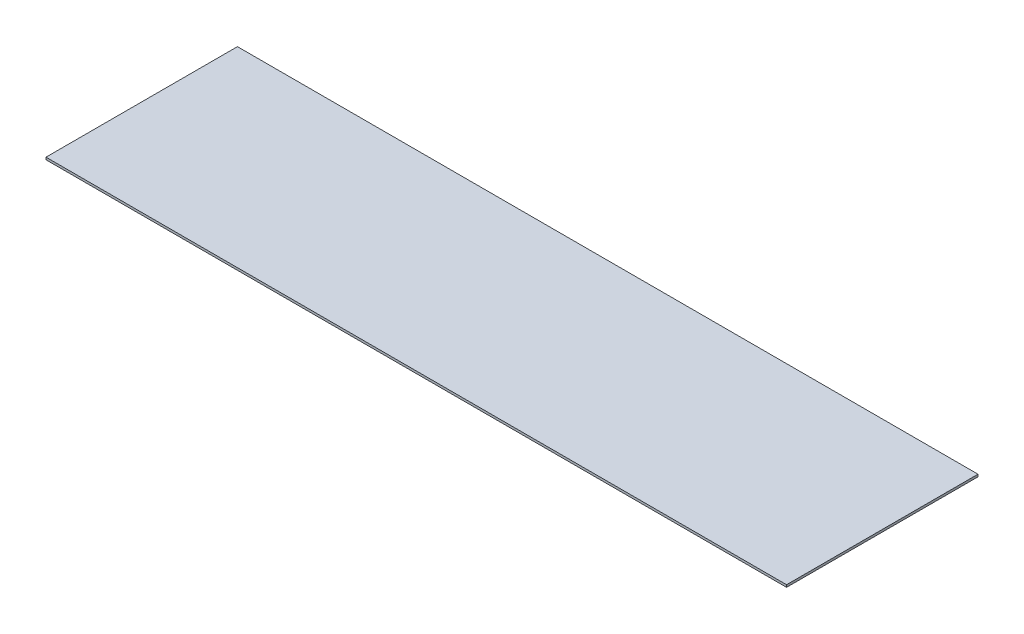
from build123d import *

# Parameters (mm, degrees)
SKETCH2_W           = 132.08
SKETCH2_H           = 1.5875
BOSS_EXTRUDE2_DEPTH = 510.9718


with BuildPart() as part:
    # Sketch2 → Boss-Extrude2 (new body)
    with BuildSketch(Plane(origin=(0, 0, 0), x_dir=(0, 0, -1), z_dir=(1, 0, 0))):
        with Locations((-46.894782158, -11.613972653)):
            Rectangle(SKETCH2_W, SKETCH2_H)
    extrude(amount=BOSS_EXTRUDE2_DEPTH)


solid = part.part
